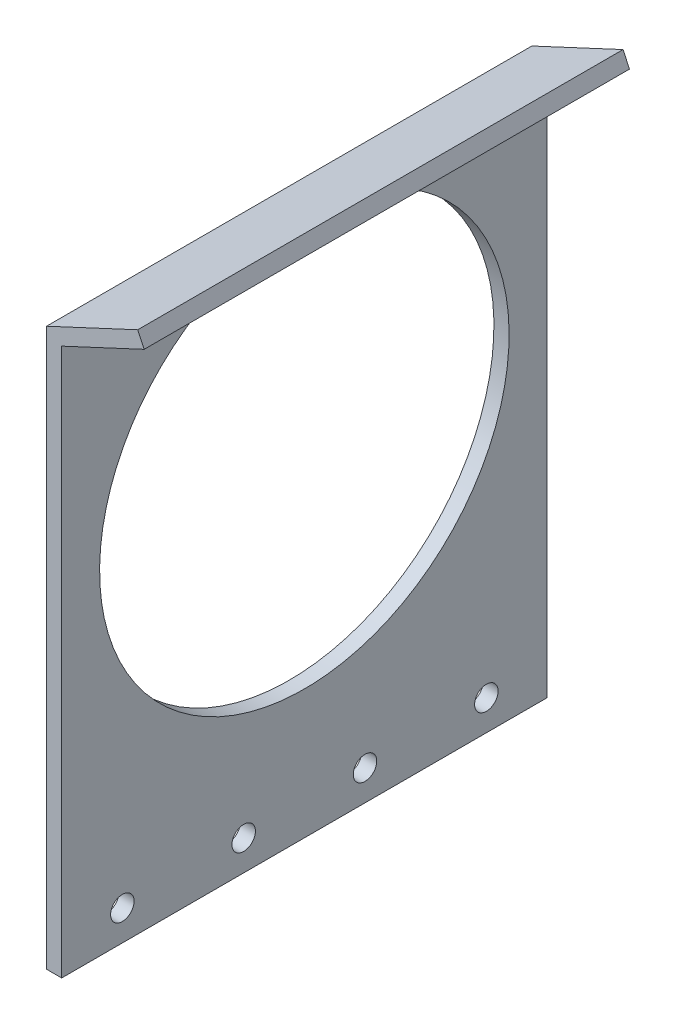
from build123d import *

# Parameters (mm, degrees)
BOSS_EXTRUDE1_DEPTH          = 101.6
F_10_0_1935_DIAMETER_HOLE1_D = 4.9149
SKETCH4_R                    = 42.8625
CUT_EXTRUDE1_DEPTH           = 127


with BuildPart() as part:
    # Sketch1 → Boss-Extrude1 (new body)
    with BuildSketch(Plane.XY):
        Polygon((0, 0), (0, 116.576698078), (19.098350362, 125.48240511), (20.440163343, 122.604877886), (3.175, 114.554), (3.175, 0), align=None)
    extrude(amount=BOSS_EXTRUDE1_DEPTH)

    # #10 (0.1935) Diameter Hole1 (through all)
    with Locations(Plane(origin=(3.175, 0, 0), x_dir=(0, 0, -1), z_dir=(1, 0, 0))):
        with Locations((-88.9, 6.35), (-63.5, 6.35), (-38.1, 6.35), (-12.7, 6.35)):
            Hole(F_10_0_1935_DIAMETER_HOLE1_D / 2)

    # Sketch4 → Cut-Extrude1 (cut)
    with BuildSketch(Plane(origin=(3.175, 0, 0), x_dir=(0, 0, -1), z_dir=(1, 0, 0))):
        with Locations((-50.8, 69.85)):
            Circle(SKETCH4_R)
    extrude(amount=-CUT_EXTRUDE1_DEPTH, mode=Mode.SUBTRACT)


solid = part.part
